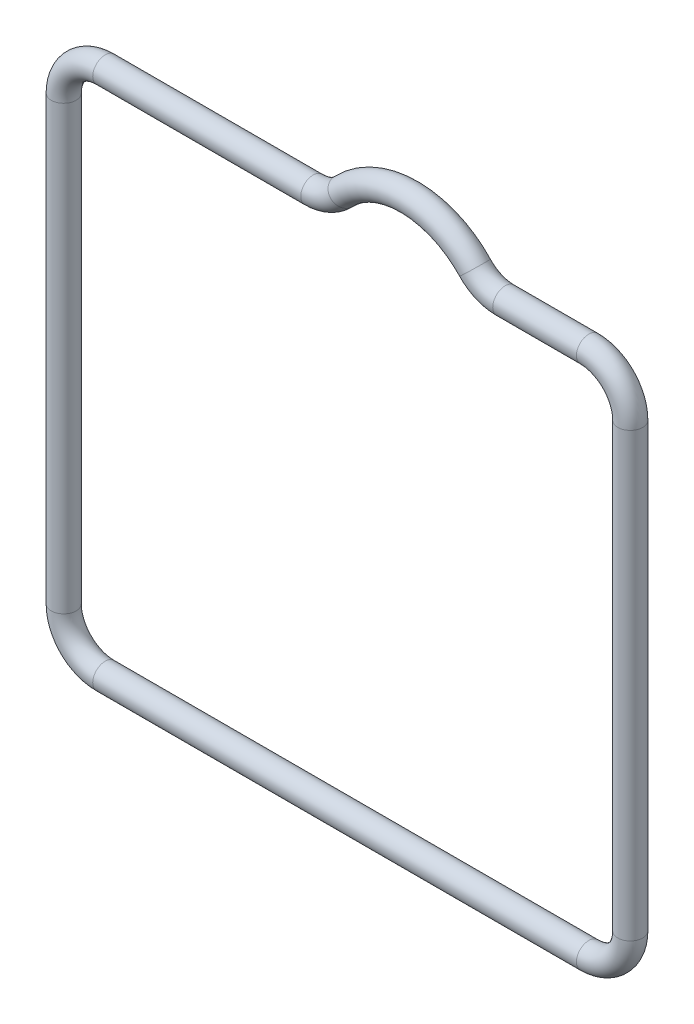
from build123d import *

# Parameters (mm, degrees)
SKETCH_3_R = 0.9


with BuildPart() as part:
    # По траектории2: sweep along a path in Эскиз1
    with BuildLine(Plane.XY) as sweep_2_path:
        Line((0, 3), (0, 35))
        ThreePointArc((0, 35), (0.878679656, 37.121320344), (3, 38))
        Line((3, 38), (18.053778005, 38))
        ThreePointArc((18.053778005, 38), (19.243251486, 38.245884382), (20.237742999, 38.943231441))
        ThreePointArc((20.237742999, 38.943231441), (25, 41), (29.762257001, 38.943231441))
        ThreePointArc((29.762257001, 38.943231441), (30.756748514, 38.245884382), (31.946221995, 38))
        Line((31.946221995, 38), (38, 38))
        ThreePointArc((38, 38), (40.121320344, 37.121320344), (41, 35))
        Line((41, 35), (41, 3))
        ThreePointArc((41, 3), (40.121320344, 0.878679656), (38, 0))
        Line((38, 0), (3, 0))
        ThreePointArc((3, 0), (0.878679656, 0.878679656), (0, 3))
    # Эскиз3 → По траектории2 (sweep)
    with BuildSketch(Plane(origin=(0, 3, 0), x_dir=(1, 0, 0), z_dir=(0, 1, 0))):
        Circle(SKETCH_3_R)
    sweep(path=sweep_2_path.line)


solid = part.part
